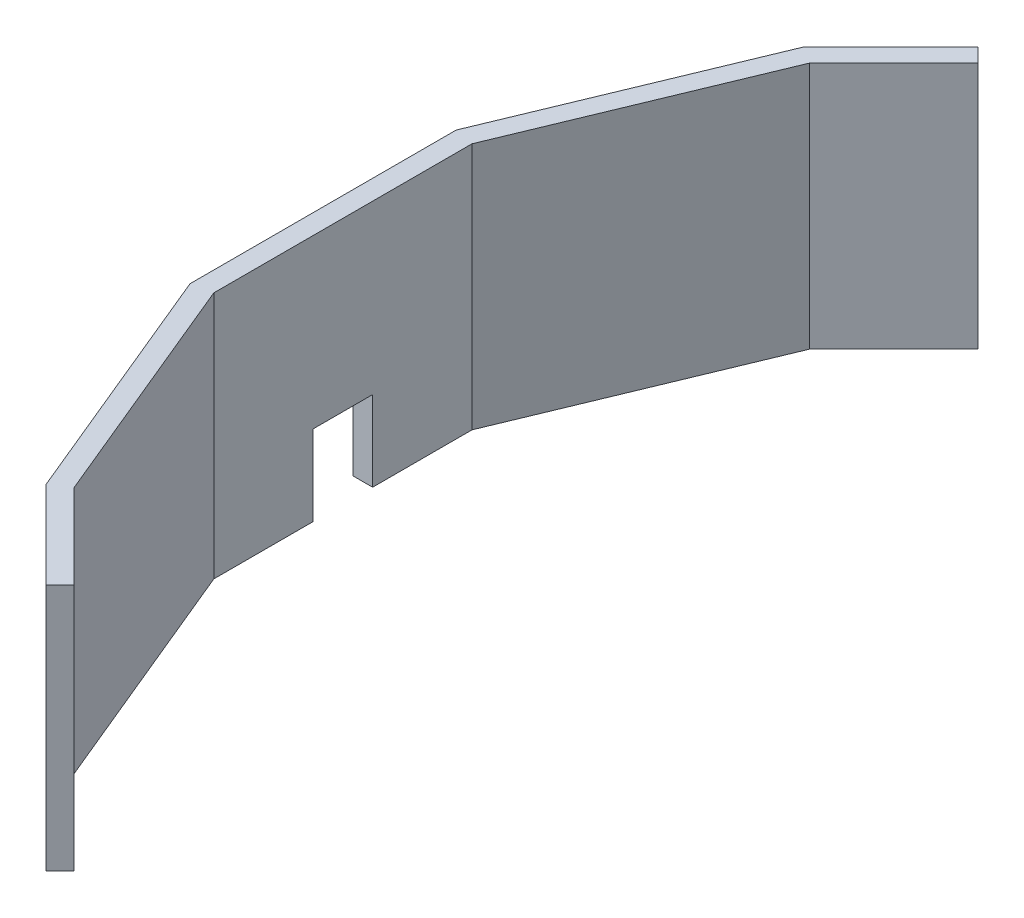
from build123d import *

# Parameters (mm, degrees)
BOSS_EXTRUDE1_DEPTH = 250
SKETCH3_W           = 60
SKETCH3_H           = 162
CUT_EXTRUDE1_DEPTH  = 20


with BuildPart() as part:
    # Sketch2 → Boss-Extrude1 (new body)
    with BuildSketch(Plane(origin=(0, 0, 0), x_dir=(1, 0, 0), z_dir=(0, 1, 0))):
        Polygon((-470.226009489, -456.083873865), (-555.28218759, -371.027695765), (-655, -130.287600634), (-655, 130.287600634), (-555.28218759, 371.027695765), (-470.226009489, 456.083873865), (-484.368145113, 470.226009489), (-572.23736889, 382.356785712), (-675, 134.265847981), (-675, -134.265847981), (-572.23736889, -382.356785712), (-484.368145113, -470.226009489), align=None)
    extrude(amount=BOSS_EXTRUDE1_DEPTH)

    # Sketch3 → Cut-Extrude1 (cut)
    with BuildSketch(Plane(origin=(-655, 0, 0), x_dir=(0, 0, -1), z_dir=(1, 0, 0))):
        Rectangle(SKETCH3_W, SKETCH3_H)
    extrude(amount=-CUT_EXTRUDE1_DEPTH, mode=Mode.SUBTRACT)


solid = part.part
